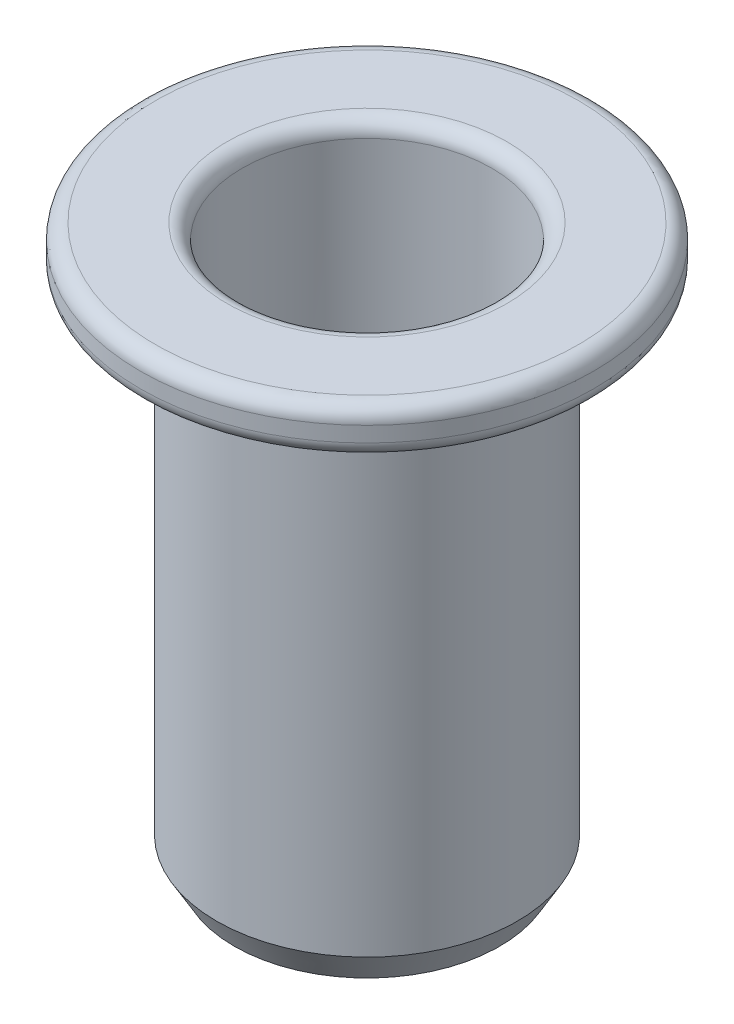
from build123d import *

# Parameters (mm, degrees)
FILLET1_R      = 0.3
CHAMFER1_SIZE  = 0.6
CHAMFER1_SIZE2 = 0.346410162
CHAMFER2_SIZE  = 0.5
CHAMFER2_SIZE2 = 0.288675135


with BuildPart() as part:
    # Sketch1 → Revolve1 (revolve)
    with BuildSketch(Plane.XY):
        Polygon((2.45, 0), (4.45, 0), (4.45, -0.9), (2.95, -0.9), (2.95, -11), (2, -11), (2, -4.9), (2.45, -4.9), align=None)
    revolve(axis=Axis((0, 0, 0), (0, -1, 0)))

    # Fillet1
    fillet1_edges = [part.edges().sort_by_distance(p)[0] for p in [
        (-4.45, -0.9, 0),
        (-4.45, 0, 0),
        (-2.45, 0, 0),
    ]]
    fillet(fillet1_edges, radius=FILLET1_R)

    # Chamfer1
    chamfer1_edges = [part.edges().sort_by_distance(p)[0] for p in [
        (-2.95, -11, 0),
    ]]
    chamfer1_side = [part.faces().sort_by_distance(p)[0] for p in [
        (-2.95, -5.95, 0),
    ]]
    chamfer(chamfer1_edges, length=CHAMFER1_SIZE, length2=CHAMFER1_SIZE2, reference=chamfer1_side[0])

    # Chamfer2
    chamfer2_edges = [part.edges().sort_by_distance(p)[0] for p in [
        (-2, -11, 0),
    ]]
    chamfer2_side = [part.faces().sort_by_distance(p)[0] for p in [
        (-2, -7.95, 0),
    ]]
    chamfer(chamfer2_edges, length=CHAMFER2_SIZE, length2=CHAMFER2_SIZE2, reference=chamfer2_side[0])


solid = part.part
